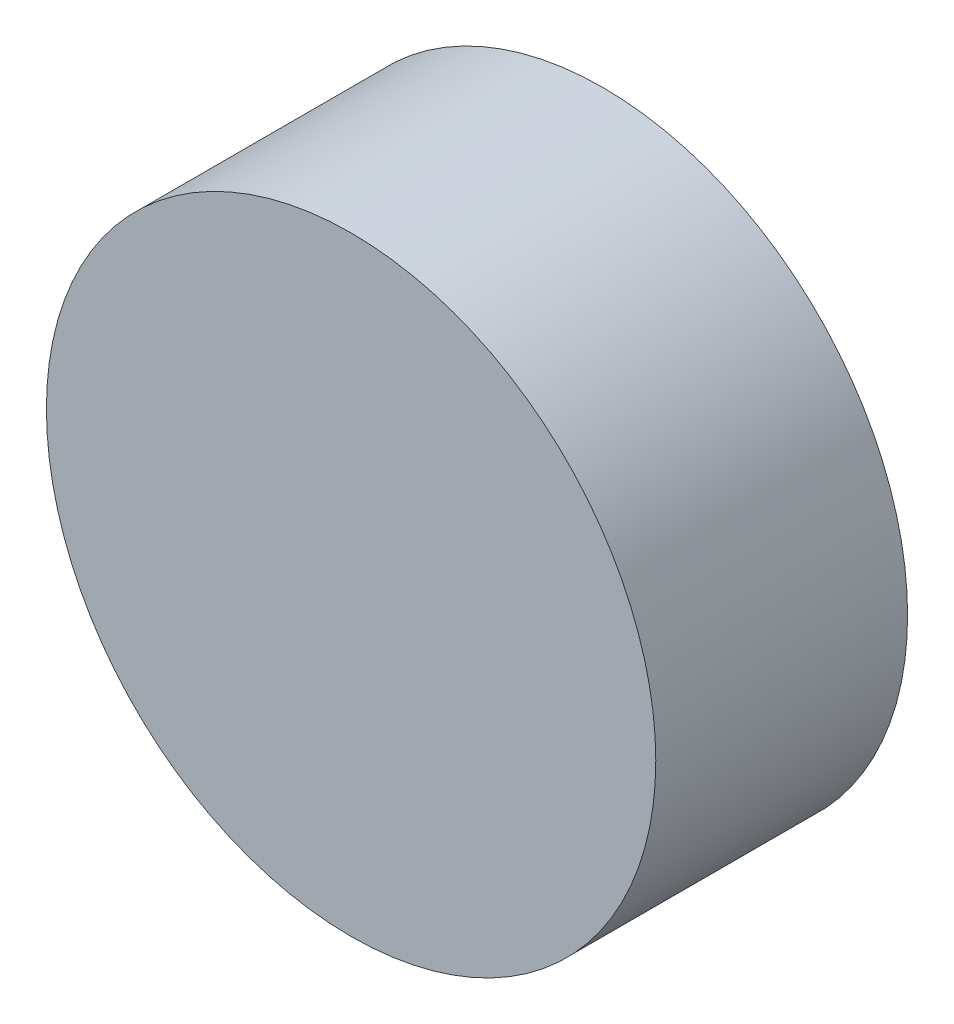
from build123d import *

# Parameters (mm, degrees)
SKETCH1_R           = 3.025
BOSS_EXTRUDE1_DEPTH = 2.5


with BuildPart() as part:
    # Sketch1 → Boss-Extrude1 (new body)
    with BuildSketch(Plane.XY):
        Circle(SKETCH1_R)
    extrude(amount=BOSS_EXTRUDE1_DEPTH)


solid = part.part
